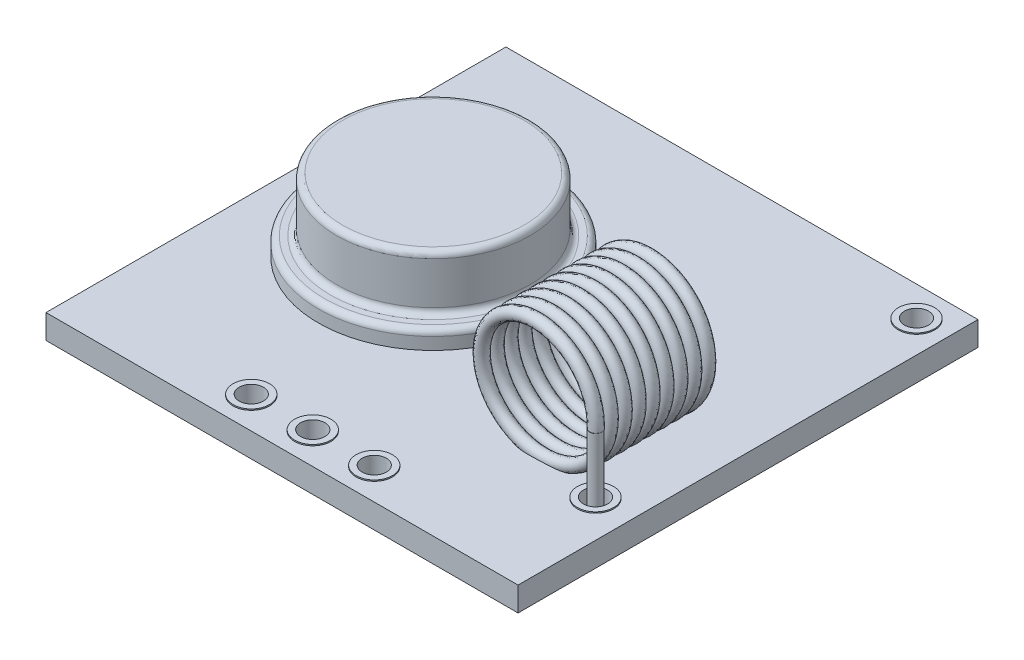
from build123d import *

# Parameters (mm, degrees)
SKETCH1_W             = 19.5
SKETCH1_H             = 19
SKETCH1_R             = 0.5
BOSS_EXTRUDE1_DEPTH   = 1
SKETCH2_R             = 0.75
SKETCH2_R_2           = 0.5
BOSS_EXTRUDE2_DEPTH   = 0.05
SKETCH12_R            = 0.252776438
BOSS_EXTRUDE3_DEPTH   = 3
BOSS_EXTRUDE3_2_DEPTH = 3
SWEEP1_PITCH          = 0.575
SWEEP1_HEIGHT         = 4.8875
SWEEP1_RADIUS         = 2.5
SWEEP1_START_ANGLE    = -180
SKETCH13_R            = 0.252776438
SKETCH14_R            = 0.5
BOSS_EXTRUDE4_DEPTH   = 0.5


with BuildPart() as part:
    # Sketch1 → Boss-Extrude1 (new body)
    with BuildSketch(Plane(origin=(0, 0, 0), x_dir=(1, 0, 0), z_dir=(0, 1, 0))):
        with Locations((9.75, 9.5)):
            Rectangle(SKETCH1_W, SKETCH1_H)
        with Locations((7.21, 1.27)):
            Circle(SKETCH1_R, mode=Mode.SUBTRACT)
        with Locations((9.75, 1.27)):
            Circle(SKETCH1_R, mode=Mode.SUBTRACT)
        with Locations((12.29, 1.27)):
            Circle(SKETCH1_R, mode=Mode.SUBTRACT)
        with Locations((18.23, 17.73)):
            Circle(SKETCH1_R, mode=Mode.SUBTRACT)
        with Locations((18, 4.7)):
            Circle(SKETCH1_R, mode=Mode.SUBTRACT)
        with Locations((13, 9.6)):
            Circle(SKETCH1_R, mode=Mode.SUBTRACT)
    extrude(amount=BOSS_EXTRUDE1_DEPTH)

    # Sketch2 → Boss-Extrude2 (add)
    with BuildSketch(Plane(origin=(0, 1, 0), x_dir=(1, 0, 0), z_dir=(0, 1, 0))):
        with Locations((18.23, 17.73)):
            Circle(SKETCH2_R)
        with Locations((18.23, 17.73)):
            Circle(SKETCH2_R_2, mode=Mode.SUBTRACT)
        with Locations((12.29, 1.27)):
            Circle(SKETCH2_R)
        with Locations((12.29, 1.27)):
            Circle(SKETCH2_R_2, mode=Mode.SUBTRACT)
        with Locations((9.75, 1.27)):
            Circle(SKETCH2_R)
        with Locations((9.75, 1.27)):
            Circle(SKETCH2_R_2, mode=Mode.SUBTRACT)
        with Locations((7.21, 1.27)):
            Circle(SKETCH2_R)
        with Locations((7.21, 1.27)):
            Circle(SKETCH2_R_2, mode=Mode.SUBTRACT)
        with Locations((13, 9.6)):
            Circle(SKETCH2_R)
        with Locations((13, 9.6)):
            Circle(SKETCH2_R_2, mode=Mode.SUBTRACT)
        with Locations((18, 4.7)):
            Circle(SKETCH2_R)
        with Locations((18, 4.7)):
            Circle(SKETCH2_R_2, mode=Mode.SUBTRACT)
    boss_extrude2 = extrude(amount=BOSS_EXTRUDE2_DEPTH)

    # Mirror1: Boss-Extrude2 across plane
    add(boss_extrude2.mirror(Plane.ZX.offset(0.5)))



with BuildPart() as body_2:
    # Sketch5 → Revolve1 (revolve)
    with BuildSketch(Plane.ZY.offset(-6.5)):
        with BuildLine():
            Line((-14.25, 1.5), (-9.5, 1.5))
            Line((-9.5, 1.5), (-9.5, 4.5))
            Line((-9.5, 4.5), (-13.25, 4.5))
            ThreePointArc((-13.25, 4.5), (-13.426776695, 4.426776695), (-13.5, 4.25))
            Line((-13.5, 4.25), (-13.5, 2.5))
            ThreePointArc((-13.5, 2.5), (-13.573223305, 2.323223305), (-13.75, 2.25))
            Line((-13.75, 2.25), (-14, 2.25))
            ThreePointArc((-14, 2.25), (-14.176776695, 2.176776695), (-14.25, 2))
            Line((-14.25, 2), (-14.25, 1.5))
        make_face()
    revolve(axis=Axis((6.5, 1, -9.5), (0, 1, 0)))


with BuildPart() as body_3:
    # Sketch12 → Boss-Extrude3 (new body)
    with BuildSketch(Plane(origin=(0, 0.5, 0), x_dir=(1, 0, 0), z_dir=(0, 1, 0))):
        with Locations((13, 9.6)):
            Circle(SKETCH12_R)
    extrude(amount=BOSS_EXTRUDE3_DEPTH)


with BuildPart() as body_4:
    # Sketch12 → Boss-Extrude3 2 (new body)
    with BuildSketch(Plane(origin=(0, 0.5, 0), x_dir=(1, 0, 0), z_dir=(0, 1, 0))):
        with Locations((18, 4.7)):
            Circle(SKETCH12_R)
    extrude(amount=BOSS_EXTRUDE3_2_DEPTH)


with BuildPart() as part_1:
    add(part.part)

    add(body_3.part)  # Sweep1 merges body 3

    add(body_4.part)  # Sweep1 merges body 4
    # Sweep1: sweep along a helix
    with BuildLine() as sweep1_path:
        add(Helix(SWEEP1_PITCH, SWEEP1_HEIGHT, SWEEP1_RADIUS, center=(15.5, 3.5, -9.6), direction=(0, 0, 1), lefthand=True, mode=Mode.PRIVATE).rotate(Axis((15.5, 3.5, -9.6), (0, 0, 1)), SWEEP1_START_ANGLE))
    # Sketch13 → Sweep1 (sweep)
    with BuildSketch(Plane(origin=(0, 3.5, 0), x_dir=(1, 0, 0), z_dir=(0, 1, 0))):
        with Locations((13, 9.6)):
            Circle(SKETCH13_R)
    sweep(path=sweep1_path.line, is_frenet=True)


    add(body_2.part)  # Boss-Extrude4 merges body 2
    # Sketch14 → Boss-Extrude4 (add)
    with BuildSketch(Plane(origin=(0, 1, 0), x_dir=(1, 0, 0), z_dir=(0, 1, 0))):
        with Locations((6.5, 11)):
            Circle(SKETCH14_R)
        with Locations((6.5, 8)):
            Circle(SKETCH14_R)
    extrude(amount=BOSS_EXTRUDE4_DEPTH)


solid = part_1.part
